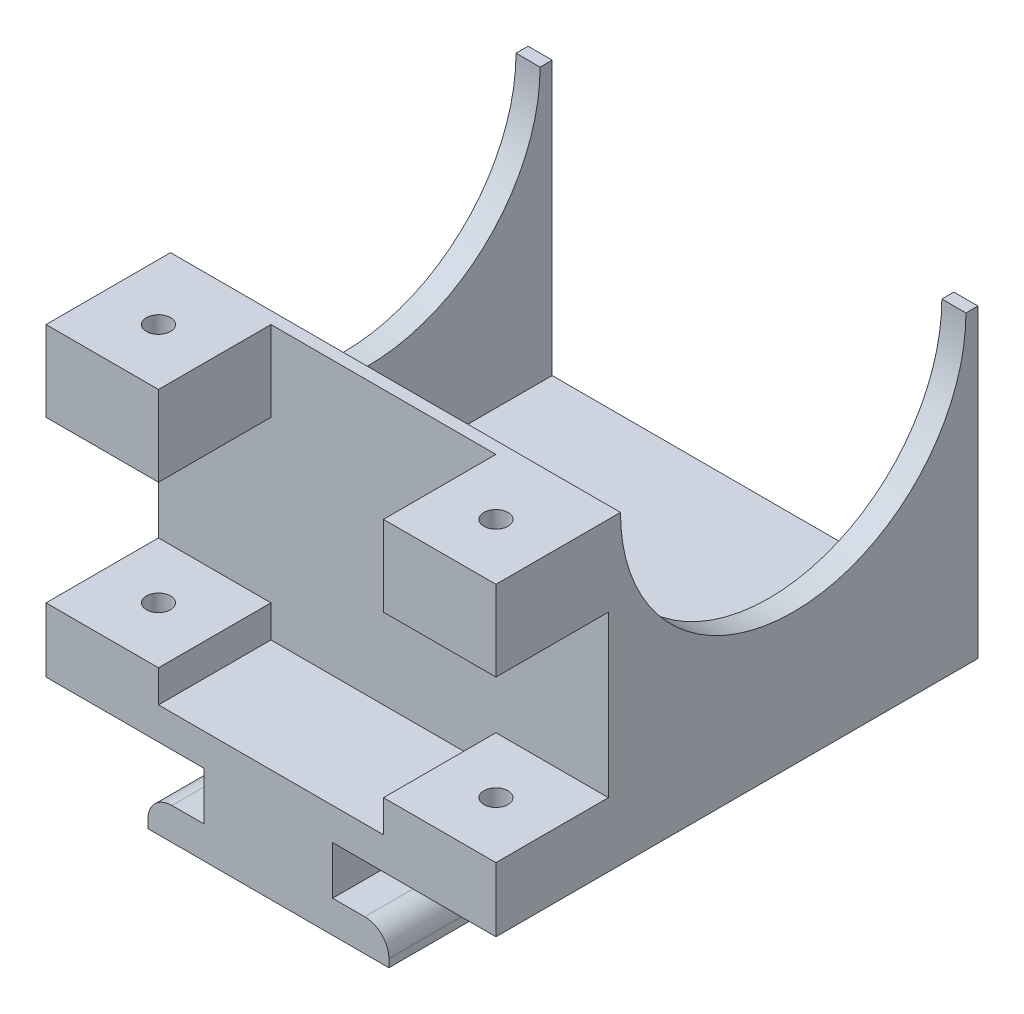
from build123d import *

# Parameters (mm, degrees)
EXTRUDE_1_DEPTH     = 30
FILLET_1_R          = 1.5
EXTRUDE_3_DEPTH     = 17
SKETCH_5_R          = 10.75
CUT_EXTRUDE_2_DEPTH = 29
SKETCH_6_W          = 7
SKETCH_6_H          = 7
SKETCH_6_R          = 0.75
EXTRUDE_4_DEPTH     = 2
EXTRUDE_START       = 15
SKETCH_8_W          = 7
SKETCH_8_H          = 7
SKETCH_8_R          = 0.75
EXTRUDE_5_DEPTH     = 5


with BuildPart() as part:
    # 草图1 → 凸台-拉伸1 (new body)
    with BuildSketch(Plane.XY):
        Polygon((-13.927970183, -1.669251604), (-4.090414819, -1.669251604), (-4.090414819, -4.669251604), (-7.590414819, -4.669251604), (-7.590414819, -6.669251604), (7.409585181, -6.669251604), (7.409585181, -4.669251604), (3.909585181, -4.669251604), (3.909585181, -1.669251604), (14.072029817, -1.669251604), (14.072029817, 0.330748396), (-13.927970183, 0.330748396), align=None)
    extrude(amount=EXTRUDE_1_DEPTH)

    # 圆角1
    fillet_1_edges = [part.edges().sort_by_distance(p)[0] for p in [
        (7.409585181, -4.669251604, 15),
        (-7.590414819, -4.669251604, 15),
    ]]
    fillet(fillet_1_edges, radius=FILLET_1_R)

    # 草图2 → 凸台-拉伸3 (add)
    with BuildSketch(Plane(origin=(0, 0.330748396, 0), x_dir=(1, 0, 0), z_dir=(0, 1, 0))):
        Polygon((-13.927970183, 0), (-12.427970183, 0), (-12.427970183, -21), (12.572029817, -21), (12.572029817, 0), (14.072029817, 0), (14.072029817, -21), (14.072029817, -23), (-13.927970183, -23), (-13.927970183, -21), align=None)
    extrude(amount=EXTRUDE_3_DEPTH)

    # 草图5 → 切除-拉伸2 (cut, through all)
    with BuildSketch(Plane.ZY.offset(13.927970183)):
        with Locations((11.5, 17.330748396)):
            Circle(SKETCH_5_R)
    extrude(amount=-CUT_EXTRUDE_2_DEPTH, mode=Mode.SUBTRACT)

    # 草图6 → 凸台-拉伸4 (add)
    with BuildSketch(Plane(origin=(0, 0.330748396, 0), x_dir=(1, 0, 0), z_dir=(0, 1, 0))):
        with Locations((-10.427970183, -26.5)):
            Rectangle(SKETCH_6_W, SKETCH_6_H)
        with Locations((-10.427970183, -26.5)):
            Circle(SKETCH_6_R, mode=Mode.SUBTRACT)
        with Locations((10.572029817, -26.5)):
            Rectangle(SKETCH_6_W, SKETCH_6_H)
        with Locations((10.572029817, -26.5)):
            Circle(SKETCH_6_R, mode=Mode.SUBTRACT)
    extrude(amount=EXTRUDE_4_DEPTH)

    # 草图8 → 凸台-拉伸5 (add)
    with BuildSketch(Plane(origin=(0, 2.330748396, 0), x_dir=(1, 0, 0), z_dir=(0, 1, 0)).offset(EXTRUDE_START)):
        with Locations((-10.427970183, -26.5)):
            Rectangle(SKETCH_8_W, SKETCH_8_H)
        with Locations((-10.427970183, -26.5)):
            Circle(SKETCH_8_R, mode=Mode.SUBTRACT)
        with Locations((10.572029817, -26.5)):
            Rectangle(SKETCH_8_W, SKETCH_8_H)
        with Locations((10.572029817, -26.5)):
            Circle(SKETCH_8_R, mode=Mode.SUBTRACT)
    extrude(amount=-EXTRUDE_5_DEPTH)


solid = part.part
